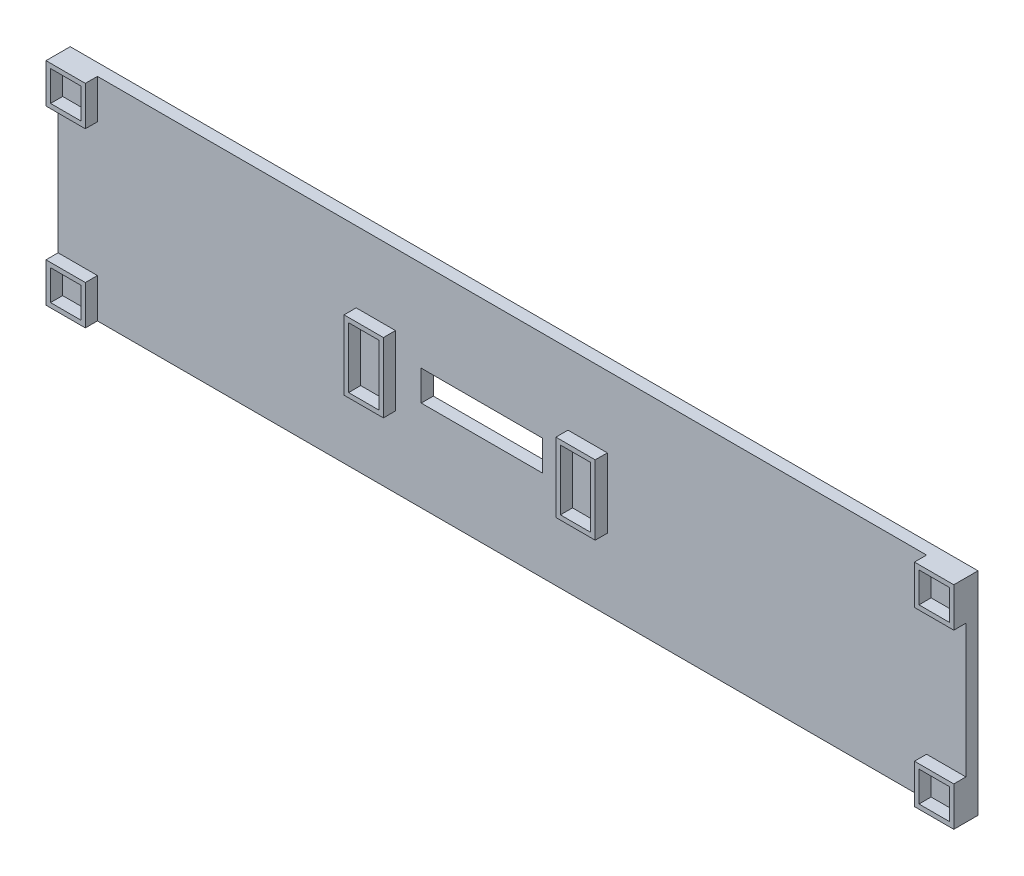
from build123d import *

# Parameters (mm, degrees)
SKICA1_W                 = 150
SKICA1_H                 = 35
P_IDAT_VYSUNUT_M2_DEPTH  = 2
SKICA2_W                 = 6.5
SKICA2_H                 = 11.5
SKICA2_W_2               = 5
SKICA2_H_2               = 10
P_IDAT_VYSUNUT_M3_DEPTH  = 2
SKICA3_W                 = 6.5
SKICA3_H                 = 6.5
SKICA3_W_2               = 5
SKICA3_H_2               = 5
P_IDAT_VYSUNUT_M4_DEPTH  = 2
SKICA4_W                 = 20
SKICA4_H                 = 5
ODEBRAT_VYSUNUT_M1_DEPTH = 2


with BuildPart() as part:
    # Skica1 → Přidat vysunutím2 (new body)
    with BuildSketch(Plane.XY):
        Rectangle(SKICA1_W, SKICA1_H)
    extrude(amount=P_IDAT_VYSUNUT_M2_DEPTH)

    # Skica2 → Přidat vysunutím3 (add)
    with BuildSketch(Plane.XY.offset(2)):
        with Locations((-22.5, 0)):
            Rectangle(SKICA2_W, SKICA2_H)
        with Locations((-22.5, 0)):
            Rectangle(SKICA2_W_2, SKICA2_H_2, mode=Mode.SUBTRACT)
        with Locations((12.5, 0)):
            Rectangle(SKICA2_W, SKICA2_H)
        with Locations((12.5, 0)):
            Rectangle(SKICA2_W_2, SKICA2_H_2, mode=Mode.SUBTRACT)
    extrude(amount=P_IDAT_VYSUNUT_M3_DEPTH)

    # Skica3 → Přidat vysunutím4 (add)
    with BuildSketch(Plane.XY.offset(2)):
        with Locations((-71.75, 14.25)):
            Rectangle(SKICA3_W, SKICA3_H)
        with Locations((-71.75, 14.25)):
            Rectangle(SKICA3_W_2, SKICA3_H_2, mode=Mode.SUBTRACT)
        with Locations((71.75, 14.25)):
            Rectangle(SKICA3_W, SKICA3_H)
        with Locations((71.75, 14.25)):
            Rectangle(SKICA3_W_2, SKICA3_H_2, mode=Mode.SUBTRACT)
        with Locations((-71.75, -14.25)):
            Rectangle(SKICA3_W, SKICA3_H)
        with Locations((-71.75, -14.25)):
            Rectangle(SKICA3_W_2, SKICA3_H_2, mode=Mode.SUBTRACT)
        with Locations((71.75, -14.25)):
            Rectangle(SKICA3_W, SKICA3_H)
        with Locations((71.75, -14.25)):
            Rectangle(SKICA3_W_2, SKICA3_H_2, mode=Mode.SUBTRACT)
    extrude(amount=P_IDAT_VYSUNUT_M4_DEPTH)

    # Skica4 → Odebrat vysunutím1 (cut)
    with BuildSketch(Plane.XY.offset(2)):
        with Locations((-5, 0)):
            Rectangle(SKICA4_W, SKICA4_H)
    extrude(amount=-ODEBRAT_VYSUNUT_M1_DEPTH, mode=Mode.SUBTRACT)


solid = part.part
